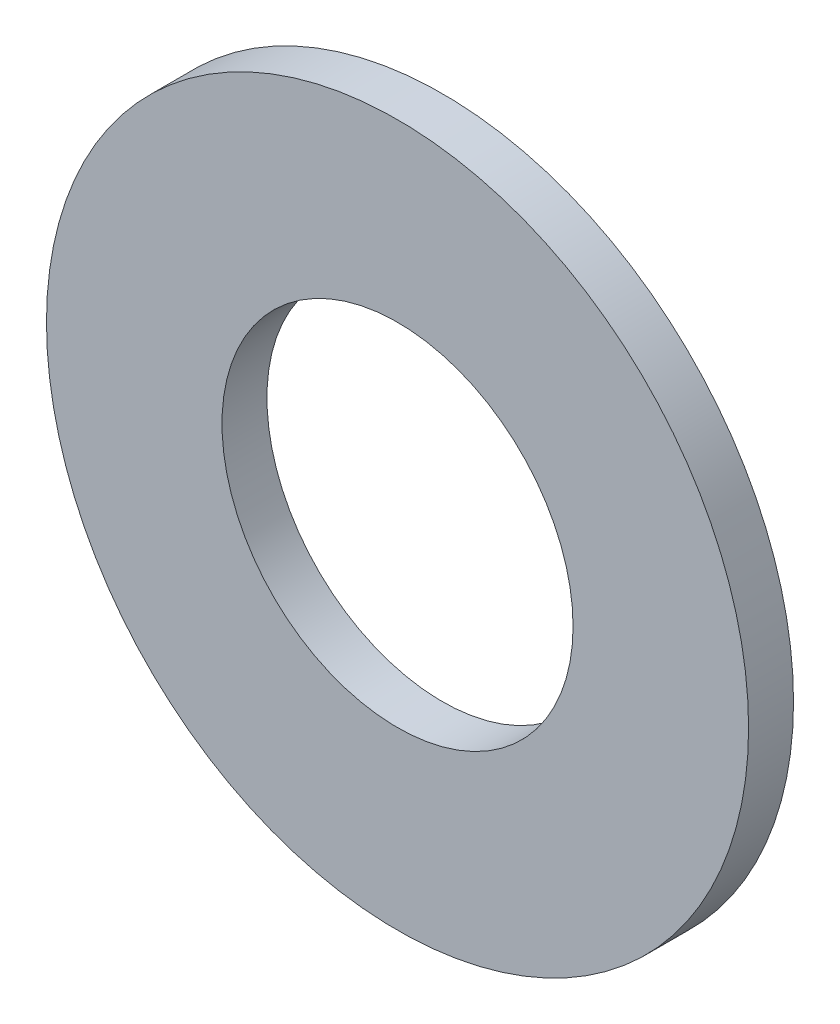
from build123d import *

# Parameters (mm, degrees)
SKETCH1_R      = 3.96875
SKETCH1_R_2    = 1.984375
EXTRUDE1_DEPTH = 0.508


with BuildPart() as part:
    # Sketch1 → Extrude1 (new body)
    with BuildSketch(Plane.XY):
        Circle(SKETCH1_R)
        Circle(SKETCH1_R_2, mode=Mode.SUBTRACT)
    extrude(amount=-EXTRUDE1_DEPTH)


solid = part.part
